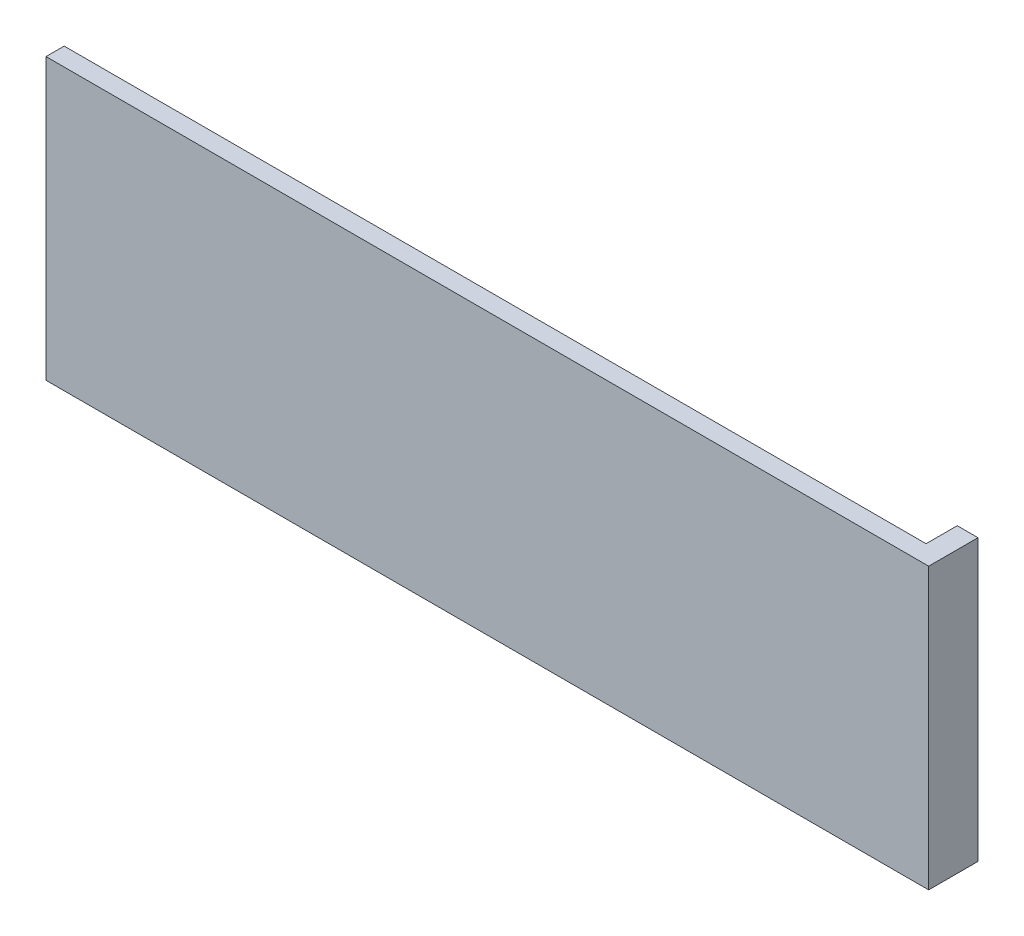
from build123d import *

# Parameters (mm, degrees)
ESQUISSE1_W          = 83
ESQUISSE1_H          = 27
BOSS_EXTRU_1_DEPTH   = 1.75
D_PLACER_LA_FACE1_BY = 2
ESQUISSE3_W          = 2
ESQUISSE3_H          = 27
BOSS_EXTRU_3_DEPTH   = 3


with BuildPart() as part:
    # Esquisse1 → Boss.-Extru.1 (new body)
    with BuildSketch(Plane.XY):
        with Locations((-41.5, 13.5)):
            Rectangle(ESQUISSE1_W, ESQUISSE1_H)
    extrude(amount=BOSS_EXTRU_1_DEPTH)

    # Déplacer la face1: a face moved outward by 2.0
    extrude(part.faces().sort_by_distance((0, 13.5, 0.875))[0], amount=D_PLACER_LA_FACE1_BY, dir=(1, 0, 0))

    # Esquisse3 → Boss.-Extru.3 (add)
    with BuildSketch(Plane(origin=(0, 0, 0), x_dir=(-1, 0, 0), z_dir=(0, 0, -1))):
        with Locations((-1, 13.5)):
            Rectangle(ESQUISSE3_W, ESQUISSE3_H)
    extrude(amount=BOSS_EXTRU_3_DEPTH)


solid = part.part
